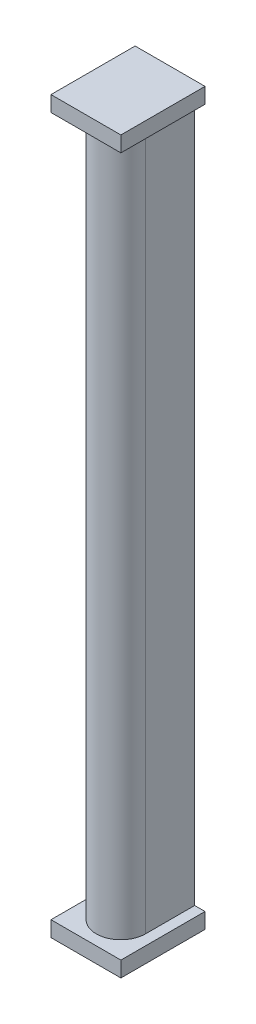
from build123d import *

# Parameters (mm, degrees)
BOSS_EXTRUDE1_DEPTH = 135
SKETCH8_W           = 13.5
SKETCH8_H           = 16.25
BOSS_EXTRUDE4_DEPTH = 3
SKETCH9_W           = 13.5
SKETCH9_H           = 16.25
BOSS_EXTRUDE5_DEPTH = 3


with BuildPart() as part:
    # Sketch5 → Boss-Extrude1 (new body)
    with BuildSketch(Plane(origin=(0, 0, 0), x_dir=(1, 0, 0), z_dir=(0, 1, 0))):
        with BuildLine():
            Line((0, 0), (9.5, 0))
            Line((9.5, 0), (9.5, -9.5))
            ThreePointArc((9.5, -9.5), (4.75, -14.25), (0, -9.5))
            Line((0, -9.5), (0, 0))
        make_face()
    extrude(amount=-BOSS_EXTRUDE1_DEPTH)

    # Sketch8 → Boss-Extrude4 (add)
    with BuildSketch(Plane.XZ.offset(135)):
        with Locations((4.75, 8.125)):
            Rectangle(SKETCH8_W, SKETCH8_H)
    extrude(amount=BOSS_EXTRUDE4_DEPTH)

    # Sketch9 → Boss-Extrude5 (add)
    with BuildSketch(Plane(origin=(0, 0, 0), x_dir=(1, 0, 0), z_dir=(0, 1, 0))):
        with Locations((4.75, -8.125)):
            Rectangle(SKETCH9_W, SKETCH9_H)
    extrude(amount=BOSS_EXTRUDE5_DEPTH)


solid = part.part
